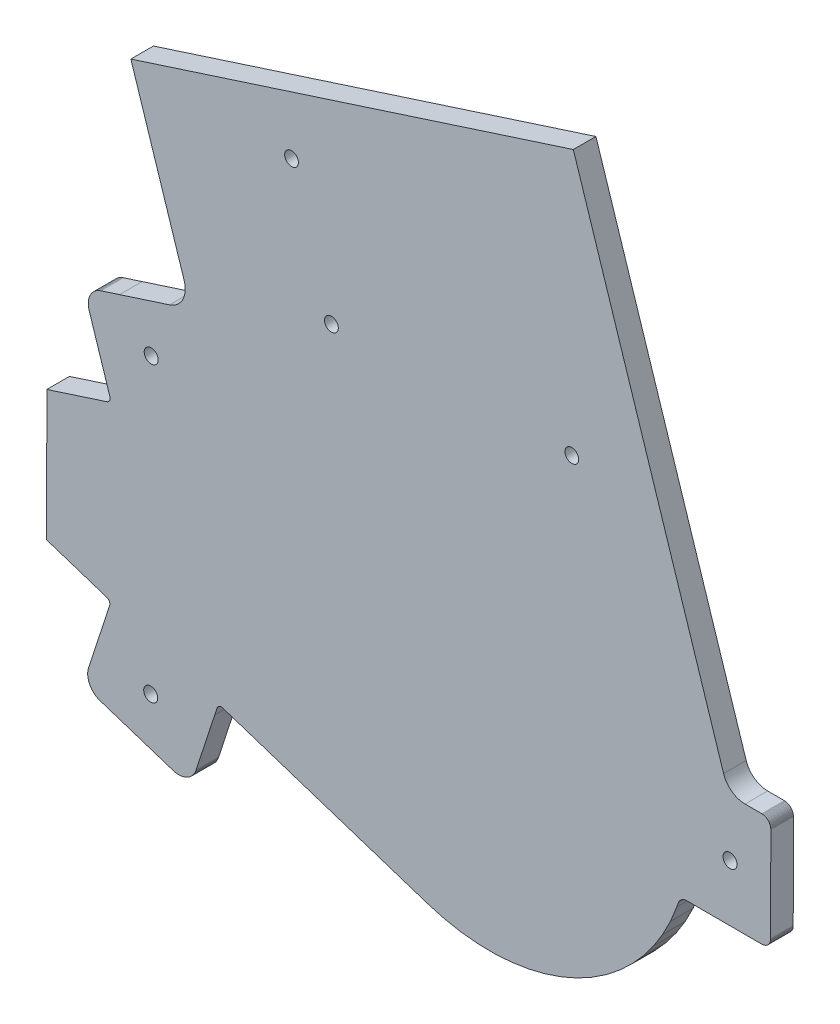
from build123d import *

# Parameters (mm, degrees)
SKETCH_1_R          = 1.55
EXTRUDE_1_DEPTH     = 5
EXTRUDE_3_DEPTH     = 5
FILLET_1_R          = 5
SKETCH_4_R          = 1.524003048
CUT_EXTRUDE_1_DEPTH = 6.0000001


with BuildPart() as part:
    # 草图1 → 凸台-拉伸1 (new body)
    with BuildSketch(Plane.XY):
        Polygon((2.700262616, 68.165545822), (-4.042447381, 65.987892096), (-4.08109335, 65.975406247), (-4.160723467, 65.953277362), (-4.241913879, 65.937804618), (-4.324101896, 65.929083876), (-4.406728606, 65.927181203), (-4.489231479, 65.932103052), (-4.571048036, 65.943826078), (-4.651612179, 65.962267321), (-4.730383966, 65.987299167), (-4.806816097, 66.018741831), (-4.880391112, 66.056393233), (-4.950606561, 66.099991711), (-5.01697867, 66.149245838), (-5.079061026, 66.203804644), (-5.136422127, 66.263309739), (-5.188675283, 66.327343203), (-5.235463619, 66.395479723), (-5.276463878, 66.467241887), (-5.311397521, 66.542144915), (-5.340027027, 66.619681745), (-5.844172765, 68.180668438), (-8.605911112, 76.7318998), (-9.950023052, 80.893705959), (-10.01791371, 81.086863512), (-10.151177365, 81.397044011), (-10.310122723, 81.694872178), (-10.493613563, 81.978244934), (-10.700342174, 82.245133406), (-10.928844155, 82.493635098), (-11.177483494, 82.721988777), (-11.444489843, 82.928559629), (-11.727965891, 83.111883981), (-12.025894842, 83.270654408), (-12.336147837, 83.403734653), (-12.656513733, 83.510174578), (-12.984721424, 83.589225104), (-13.318424984, 83.640315833), (-13.65524085, 83.66309237), (-13.99278513, 83.657386581), (-14.328643761, 83.623238898), (-14.660424688, 83.560883507), (-14.985765249, 83.470785613), (-27.018413223, 79.584663531), (-31.162998665, 78.246116508), (-31.479588077, 78.12889787), (-31.785159865, 77.985403845), (-32.077551556, 77.816651338), (-32.35466739, 77.623851084), (-32.614537992, 77.408370508), (-32.855312917, 77.171733705), (-33.075282034, 76.915643836), (-33.176523981, 76.775386808), (-33.272865385, 76.641923498), (-33.446670928, 76.352514832), (-33.595451712, 76.049471996), (-33.718145904, 75.734968682), (-33.813892719, 75.411245995), (-33.881995207, 75.080590034), (-33.921972325, 74.745376686), (-33.933544195, 74.407982195), (-33.916624588, 74.0708204), (-33.871328481, 73.736283144), (-33.797994379, 73.406755217), (-33.740078318, 73.21037431), (-32.130688911, 68.227192387), (-29.130074856, 58.936342632), (-29.107945965, 58.85671624), (-29.092473227, 58.775522103), (-29.083752472, 58.693341537), (-29.081842354, 58.610711088), (-29.086772593, 58.528204505), (-29.098494674, 58.446395397), (-29.116935924, 58.365827528), (-29.141960312, 58.287059453), (-29.173410427, 58.210627336), (-29.211061828, 58.137052321), (-29.254660314, 58.066833147), (-29.30391444, 58.000461037), (-29.35847324, 57.938382407), (-29.417978348, 57.881013856), (-29.482011806, 57.828764425), (-29.550149256, 57.781976091), (-29.621910489, 57.74097583), (-29.696813524, 57.706038462), (-29.774342903, 57.677408942), (-43.096769974, 53.374745745), (-43.108623201, 46.677548546), (-43.135967788, 31.227571981), (-43.147821016, 24.530374781), (-29.84070775, 20.180578661), (-29.763280197, 20.151674887), (-29.688501299, 20.116474462), (-29.616885646, 20.075220442), (-29.548914237, 20.028193075), (-29.485066137, 19.975713583), (-29.425764462, 19.918140346), (-29.37142575, 19.855867118), (-29.322406876, 19.789319215), (-29.279057215, 19.718949878), (-29.241666487, 19.645242047), (-29.210487119, 19.568699083), (-29.18574171, 19.489841059), (-29.167585762, 19.409210281), (-29.156153348, 19.327354604), (-29.151515186, 19.244834811), (-29.153717779, 19.162213504), (-29.162729391, 19.080056871), (-29.178489429, 18.9989236), (-29.200900049, 18.91937045), (-32.234382549, 9.639205904), (-33.861401078, 4.661750167), (-33.920011915, 4.465575499), (-33.994512004, 4.136308289), (-34.040992003, 3.801934397), (-34.059104978, 3.46483088), (-34.048727465, 3.127401267), (-34.009937168, 2.79204851), (-33.943005538, 2.46115728), (-33.848405225, 2.137093977), (-33.726825064, 1.822158327), (-33.579117901, 1.518594468), (-33.406337886, 1.228568663), (-33.20972468, 0.954146919), (-32.990663435, 0.697280019), (-32.75072764, 0.459799868), (-32.491621418, 0.243397506), (-32.215189791, 0.049613349), (-31.923397267, -0.120169369), (-31.618335326, -0.264744141), (-31.302162821, -0.383082691), (-27.162341469, -1.736295836), (-15.143524753, -5.664978587), (-14.81850516, -5.756231324), (-14.486947027, -5.819757019), (-14.151211382, -5.855097068), (-13.813689413, -5.861997642), (-13.476795041, -5.840417216), (-13.142912717, -5.790504308), (-12.814427263, -5.71261605), (-12.493686597, -5.607307022), (-12.182964475, -5.475325827), (-11.88447539, -5.317614771), (-11.600352196, -5.135295002), (-11.332616312, -4.929670579), (-11.083170217, -4.702198451), (-10.853790027, -4.454503429), (-10.646117994, -4.188348396), (-10.461625242, -3.905630651), (-10.301626638, -3.608363251), (-10.16726587, -3.298663866), (-10.098691902, -3.105744346), (-5.947866403, 9.592681955), (-5.438198323, 11.151876182), (-5.409294542, 11.22930746), (-5.374095977, 11.304088225), (-5.332841955, 11.375704809), (-5.285812733, 11.443671558), (-5.233333238, 11.507521521), (-5.175761867, 11.566821336), (-5.113486769, 11.62116377), (-5.046940739, 11.67017706), (-4.976571399, 11.713528583), (-4.902863568, 11.750919312), (-4.826320608, 11.782096817), (-4.747460711, 11.806847811), (-4.666831802, 11.825000036), (-4.584974261, 11.836433379), (-4.502454473, 11.841068746), (-4.419835018, 11.838871745), (-4.337678386, 11.829860132), (-4.256543259, 11.814096366), (-4.176991971, 11.79168575), (-4.138390434, 11.779066907), (2.596568977, 9.577559339), (41.206755853, -3.043245386), (44.835853967, -4.059707758), (48.538621001, -4.76187842), (52.287893751, -5.144612509), (56.056169609, -5.205097412), (59.815792753, -4.942893259), (63.539192599, -4.35991786), (67.199040249, -3.460451756), (70.768494442, -2.25109337), (74.221358093, -0.740714696), (77.532309378, 1.059601624), (80.677058339, 3.136647701), (83.632518429, 5.475186957), (86.377030209, 8.058061759), (87.602333867, 9.427109434), (88.89042119, 10.866321838), (91.154296652, 13.879367199), (93.152017545, 17.075087854), (94.868939221, 20.430044084), (96.292471309, 23.919615337), (96.609789101, 24.835664699), (96.669132982, 24.991373904), (96.741237474, 25.141599239), (96.825594103, 25.285305974), (96.921619945, 25.421489309), (97.028642774, 25.549204209), (97.145930873, 25.667569074), (97.272663214, 25.775758341), (97.407974206, 25.873024758), (97.550894069, 25.958688312), (97.700453181, 26.032158396), (97.855607551, 26.092922769), (98.015298449, 26.14055862), (98.178377898, 26.174736429), (98.343757694, 26.195219703), (98.510260398, 26.201868965), (100.823900468, 26.197774103), (115.042417198, 26.172609051), (115.216744179, 26.179911293), (115.389756892, 26.202377817), (115.560173536, 26.239839527), (115.726667402, 26.292011924), (115.887986084, 26.358494892), (116.042891895, 26.438787707), (116.190206551, 26.532274055), (116.328811209, 26.638244385), (116.457661358, 26.755892156), (116.575757031, 26.884321342), (116.682217329, 27.022553748), (116.776235731, 27.16954027), (116.857065194, 27.324160914), (116.924122492, 27.485239519), (116.976883908, 27.651547666), (117.014944876, 27.821823193), (117.038034876, 27.994766453), (117.045957871, 28.169066487), (117.050869275, 30.944060686), (117.078213862, 46.394037251), (117.083125265, 49.16903145), (117.075819297, 49.343358438), (117.053341618, 49.516382346), (117.01588362, 49.686791533), (116.963711223, 49.8532854), (116.897224523, 50.014600362), (116.816942884, 50.169506154), (116.723445366, 50.316824555), (116.617475043, 50.455432938), (116.499834716, 50.584279348), (116.371401818, 50.702382479), (116.233173137, 50.808842771), (116.086190321, 50.90284999), (115.931569697, 50.983690629), (115.770487359, 51.050744208), (115.604179213, 51.103505624), (115.433896241, 51.141570331), (115.260964138, 51.164649135), (115.086664104, 51.17257213), (100.868147374, 51.197737182), (98.554507303, 51.201832045), (98.388029174, 51.209066918), (98.222722919, 51.230135466), (98.059765472, 51.264890321), (97.900244194, 51.313091138), (97.745305886, 51.374404338), (97.596007777, 51.448403364), (97.453392036, 51.534572281), (97.31842619, 51.632317055), (97.192077606, 51.740954245), (97.075209224, 51.859733538), (96.968639143, 51.987826472), (96.873095957, 52.124348861), (96.789248542, 52.268353296), (96.717676262, 52.418832922), (96.658883923, 52.574751214), (96.344810698, 53.491916199), (94.933639731, 56.986506396), (93.228604509, 60.347520937), (91.24220817, 63.550291135), (88.989012304, 66.571329301), (87.706027505, 68.015095917), (86.485577602, 69.388470417), (83.750225738, 71.981043913), (80.803062001, 74.330030098), (77.665684958, 76.418194778), (77.371106218, 76.579730896), (74.361127073, 78.230216022), (70.913631418, 79.752811222), (67.34848041, 80.974796994), (63.691839564, 81.887208671), (59.97052663, 82.48336031), (56.211855182, 82.758874775), (52.443388832, 82.711728876), (48.692784789, 82.342268544), (44.987555446, 81.653209255), (41.354882049, 80.649599106), (29.01825498, 76.665309585), align=None)
        with Locations((-20.001051901, 71.342431193)):
            Circle(SKETCH_1_R, mode=Mode.SUBTRACT)
        with Locations((-20.115848626, 6.481050779)):
            Circle(SKETCH_1_R, mode=Mode.SUBTRACT)
        with Locations((108.066034572, 38.685515468)):
            Circle(SKETCH_1_R, mode=Mode.SUBTRACT)
    extrude(amount=-EXTRUDE_1_DEPTH)

    # 草图3 → 凸台-拉伸3 (add)
    with BuildSketch(Plane(origin=(0, 0, -5), x_dir=(-1, 0, 0), z_dir=(0, 0, -1))):
        Polygon((11.17935545, 84.700117461), (24.509605797, 125.974892537), (-73.388927453, 157.592556216), (-107.754518551, 51.185549139), (-98.554507303, 51.201832045), (-98.388029174, 51.209066918), (-98.222722919, 51.230135466), (-98.059765472, 51.264890321), (-97.900244194, 51.313091138), (-97.745305886, 51.374404338), (-97.596007777, 51.448403364), (-97.453392036, 51.534572281), (-97.31842619, 51.632317055), (-97.192077606, 51.740954245), (-97.075209224, 51.859733538), (-96.968639143, 51.987826472), (-96.873095957, 52.124348861), (-96.789248542, 52.268353296), (-96.717676262, 52.418832922), (-96.658883923, 52.574751214), (-96.344810698, 53.491916199), (-94.933639731, 56.986506396), (-93.228604509, 60.347520937), (-91.24220817, 63.550291135), (-88.989012304, 66.571329301), (-87.706027505, 68.015095917), (-86.485577602, 69.388470417), (-83.750225738, 71.981043913), (-80.803062001, 74.330030098), (-77.665684958, 76.418194778), (-77.371106218, 76.579730896), (-74.361127073, 78.230216022), (-70.913631418, 79.752811222), (-67.34848041, 80.974796994), (-63.691839564, 81.887208671), (-59.97052663, 82.48336031), (-56.211855182, 82.758874775), (-52.443388832, 82.711728876), (-48.692784789, 82.342268544), (-44.987555446, 81.653209255), (-41.354882049, 80.649599106), (-29.01825498, 76.665309585), (-2.700262616, 68.165545822), (4.042447381, 65.987892096), (4.08109335, 65.975406247), (4.160723467, 65.953277362), (4.241913879, 65.937804618), (4.324101896, 65.929083876), (4.406728606, 65.927181203), (4.489231479, 65.932103052), (4.571048036, 65.943826078), (4.651612179, 65.962267321), (4.730383966, 65.987299167), (4.806816097, 66.018741831), (4.880391112, 66.056393233), (4.950606561, 66.099991711), (5.01697867, 66.149245838), (5.079061026, 66.203804644), (5.136422127, 66.263309739), (5.188675283, 66.327343203), (5.235463619, 66.395479723), (5.276463878, 66.467241887), (5.311397521, 66.542144915), (5.340027027, 66.619681745), (5.844172765, 68.180668438), (8.605911112, 76.7318998), (9.950023052, 80.893705959), (14.985765249, 83.470785613), align=None)
    extrude(amount=-EXTRUDE_3_DEPTH)

    # 圆角1
    fillet_1_edges = [part.edges().sort_by_distance(p)[0] for p in [
        (-11.17935545, 84.700117461, -2.5),
        (107.754518551, 51.185549139, -2.5),
    ]]
    fillet(fillet_1_edges, radius=FILLET_1_R)

    # 草图4 → 切除-拉伸1 (cut, through all)
    with BuildSketch(Plane.XY):
        with Locations((73.055947512, 98.798016076)):
            Circle(SKETCH_4_R)
        with Locations((11.045973508, 124.681088628)):
            Circle(SKETCH_4_R)
        with Locations((19.867058424, 97.368151032)):
            Circle(SKETCH_4_R)
    extrude(amount=-CUT_EXTRUDE_1_DEPTH, mode=Mode.SUBTRACT)


solid = part.part
